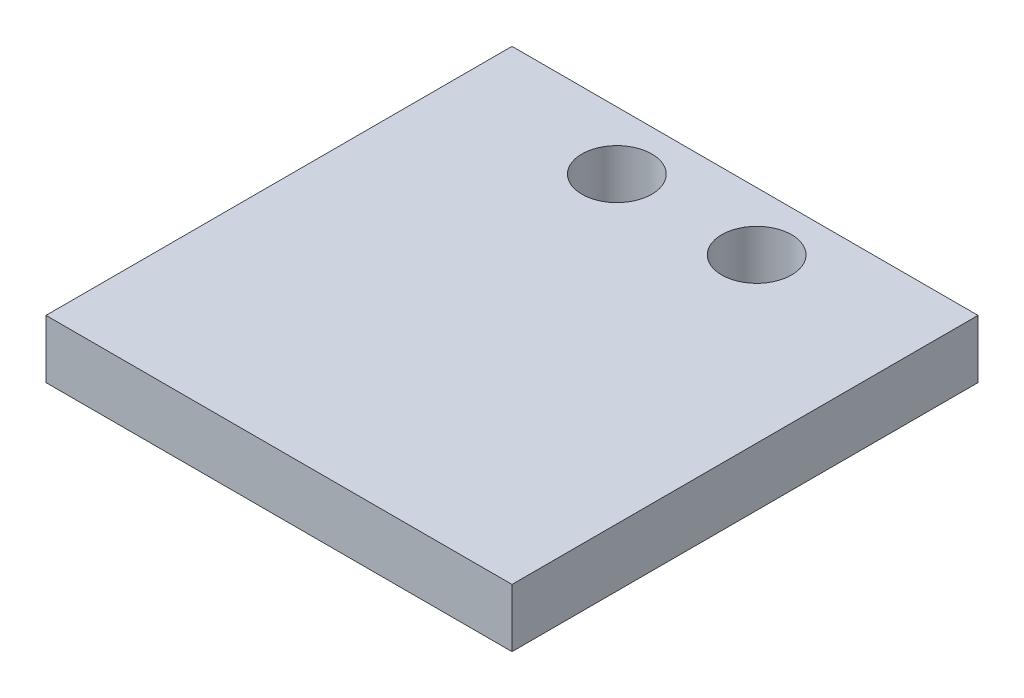
from build123d import *

# Parameters (mm, degrees)
SKETCH1_W           = 20
SKETCH1_H           = 20
SKETCH1_R           = 1.5
BOSS_EXTRUDE1_DEPTH = 2.5


with BuildPart() as part:
    # Sketch1 → Boss-Extrude1 (new body)
    with BuildSketch(Plane(origin=(0, 0, 0), x_dir=(1, 0, 0), z_dir=(0, 1, 0))):
        Rectangle(SKETCH1_W, SKETCH1_H)
        with Locations((-3, 7.5)):
            Circle(SKETCH1_R, mode=Mode.SUBTRACT)
        with Locations((3, 7.5)):
            Circle(SKETCH1_R, mode=Mode.SUBTRACT)
    extrude(amount=BOSS_EXTRUDE1_DEPTH)


solid = part.part
